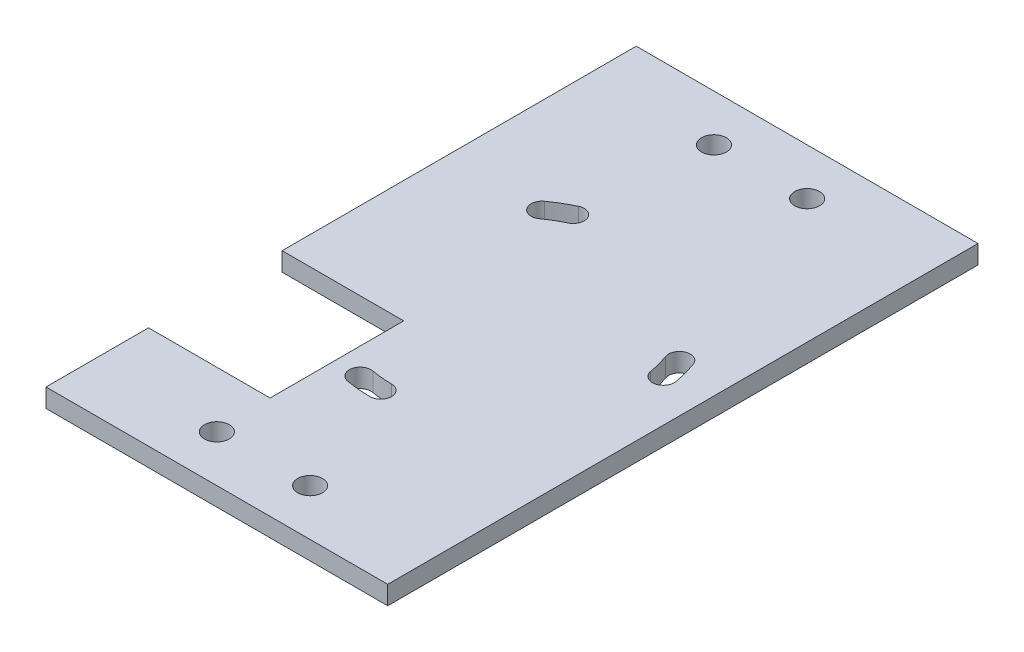
from build123d import *

# Parameters (mm, degrees)
SKIZZE3_W                            = 190
SKIZZE3_H                            = 6
AUFSATZ_LINEAR_AUSTRAGEN2_DEPTH      = 55
AUFSATZ_LINEAR_AUSTRAGEN2_DEPTH_BACK = 55
SCHNITT_LINEAR_AUSTRAGEN5_DEPTH      = 169.5
OUTLINETOP_R                         = 3
SCHNITT_LINEAR_AUSTRAGEN6_DEPTH      = 169.5
SKIZZE8_W                            = 39.137679275
SKIZZE8_H                            = 43
SCHNITT_LINEAR_AUSTRAGEN7_DEPTH      = 169.5
SKIZZE9_R                            = 4
SCHNITT_LINEAR_AUSTRAGEN8_DEPTH      = 169.5


with BuildPart() as part:
    # Skizze3 → Aufsatz-Linear austragen2 (new body, two sides)
    with BuildSketch(Plane(origin=(0, 0, 0), x_dir=(0, 0, -1), z_dir=(1, 0, 0))) as aufsatz_linear_austragen2_sk:
        with Locations((-190, 166.5)):
            Rectangle(SKIZZE3_W, SKIZZE3_H)
    extrude(amount=AUFSATZ_LINEAR_AUSTRAGEN2_DEPTH)
    extrude(aufsatz_linear_austragen2_sk.sketch, amount=-AUFSATZ_LINEAR_AUSTRAGEN2_DEPTH_BACK)

    # Holes → Schnitt-Linear austragen5 (cut)
    with BuildSketch(Plane(origin=(0, 0, 0), x_dir=(1, 0, 0), z_dir=(0, 1, 0))):
        with BuildLine():
            ThreePointArc((-19.706276733, -148.936330777), (-23.210222992, -150.810105621), (-26.537525439, -152.982139225))
            ThreePointArc((-26.537525439, -152.982139225), (-27.342866764, -157.865931333), (-22.459074657, -158.671272659))
            ThreePointArc((-22.459074657, -158.671272659), (-19.643132597, -156.833050591), (-16.677694436, -155.247249036))
            ThreePointArc((-16.677694436, -155.247249036), (-15.036526455, -150.577498758), (-19.706276733, -148.936330777))
        make_face()
        with BuildLine():
            ThreePointArc((44.855396174, -182.090783424), (43.995374204, -178.211475011), (42.800520871, -174.421884392))
            ThreePointArc((42.800520871, -174.421884392), (38.314526197, -172.330030721), (36.222672526, -176.816025395))
            ThreePointArc((36.222672526, -176.816025395), (37.23389342, -180.023208327), (37.961741903, -183.306320668))
            ThreePointArc((37.961741903, -183.306320668), (42.01633766, -186.145379182), (44.855396174, -182.090783424))
        make_face()
        with BuildLine():
            ThreePointArc((-8.120828878, -234.817568107), (-4.183818236, -235.354800603), (-0.214966211, -235.546855679))
            ThreePointArc((-0.214966211, -235.546855679), (3.301513476, -232.063413328), (-0.181928876, -228.546933641))
            ThreePointArc((-0.181928876, -228.546933641), (-3.540823214, -228.384394775), (-6.872769749, -227.929727487))
            ThreePointArc((-6.872769749, -227.929727487), (-10.940719624, -230.749618233), (-8.120828878, -234.817568107))
        make_face()
    extrude(amount=SCHNITT_LINEAR_AUSTRAGEN5_DEPTH, mode=Mode.SUBTRACT)

    # OutlineTop → Schnitt-Linear austragen6 (cut)
    with BuildSketch(Plane(origin=(0, 0, 0), x_dir=(1, 0, 0), z_dir=(0, 1, 0))):
        with Locations((-15, -270)):
            Circle(OUTLINETOP_R)
        with Locations((15, -270)):
            Circle(OUTLINETOP_R)
        with Locations((-15, -110)):
            Circle(OUTLINETOP_R)
        with Locations((15, -110)):
            Circle(OUTLINETOP_R)
    extrude(amount=SCHNITT_LINEAR_AUSTRAGEN6_DEPTH, mode=Mode.SUBTRACT)

    # Skizze8 → Schnitt-Linear austragen7 (cut)
    with BuildSketch(Plane(origin=(0, 0, 0), x_dir=(1, 0, 0), z_dir=(0, 1, 0))):
        with Locations((-35.431160363, -230.5)):
            Rectangle(SKIZZE8_W, SKIZZE8_H)
    extrude(amount=SCHNITT_LINEAR_AUSTRAGEN7_DEPTH, mode=Mode.SUBTRACT)

    # Skizze9 → Schnitt-Linear austragen8 (cut)
    with BuildSketch(Plane(origin=(0, 0, 0), x_dir=(1, 0, 0), z_dir=(0, 1, 0))):
        with Locations((-15, -110)):
            Circle(SKIZZE9_R)
        with Locations((15, -110)):
            Circle(SKIZZE9_R)
        with Locations((15, -270)):
            Circle(SKIZZE9_R)
        with Locations((-15, -270)):
            Circle(SKIZZE9_R)
    extrude(amount=SCHNITT_LINEAR_AUSTRAGEN8_DEPTH, mode=Mode.SUBTRACT)


solid = part.part
